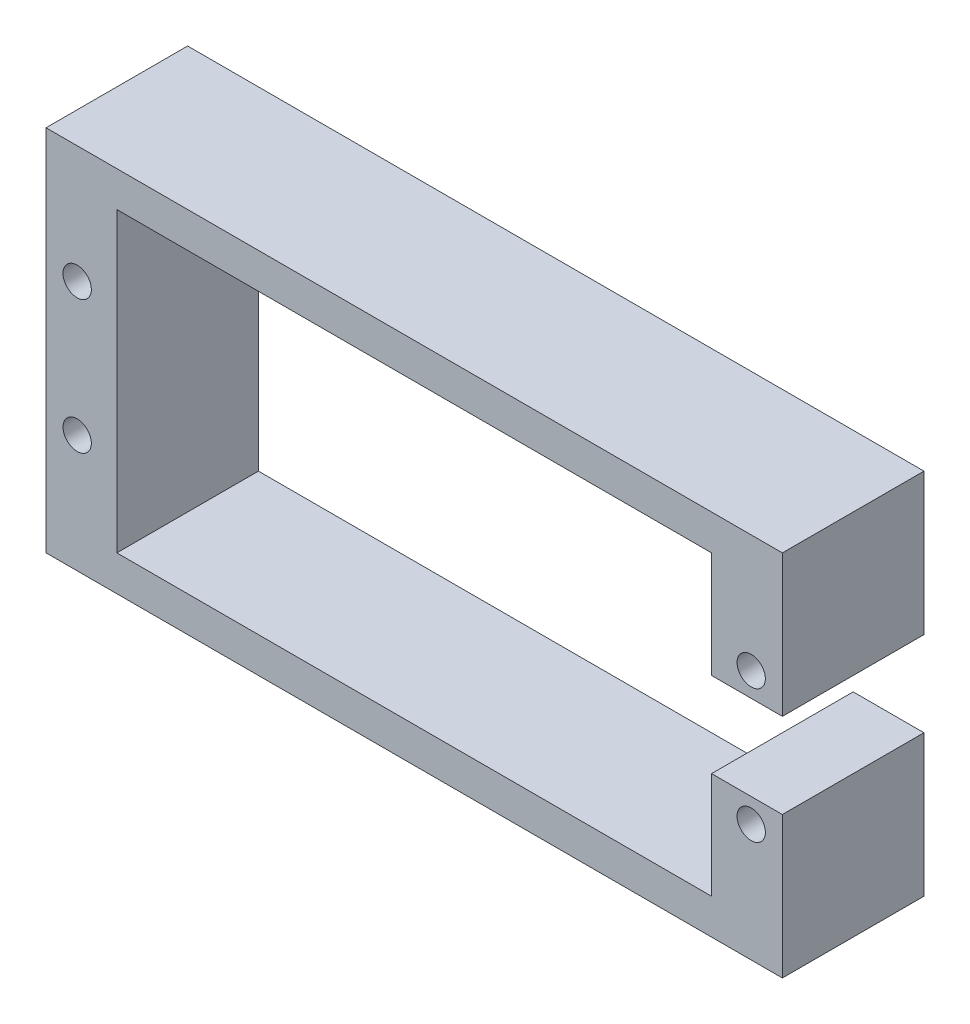
from build123d import *

# Parameters (mm, degrees)
SKETCH_1_R      = 1
EXTRUDE_1_DEPTH = 10


with BuildPart() as part:
    # 草圖1 → 填料-伸長1 (new body)
    with BuildSketch(Plane.XY):
        Polygon((-21, 10.5), (21, 10.5), (21, 3), (26, 3), (26, 13), (-26, 13), (-26, -13), (26, -13), (26, -3), (21, -3), (21, -10.5), (-21, -10.5), align=None)
        with Locations((-23.8, 4.7)):
            Circle(SKETCH_1_R, mode=Mode.SUBTRACT)
        with Locations((23.8, 4.7)):
            Circle(SKETCH_1_R, mode=Mode.SUBTRACT)
        with Locations((23.8, -4.7)):
            Circle(SKETCH_1_R, mode=Mode.SUBTRACT)
        with Locations((-23.8, -4.7)):
            Circle(SKETCH_1_R, mode=Mode.SUBTRACT)
    extrude(amount=EXTRUDE_1_DEPTH)


solid = part.part
